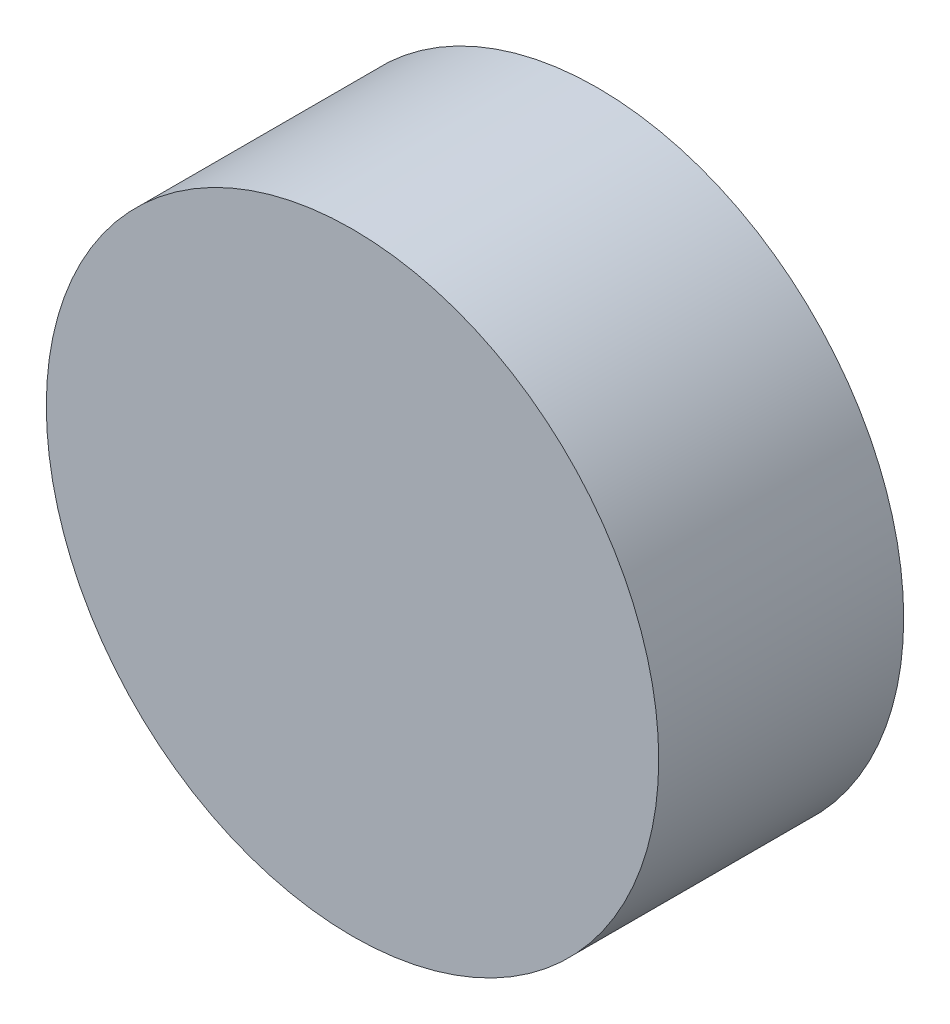
from build123d import *

# Parameters (mm, degrees)
SKIZZE1_R                       = 2.5
AUFSATZ_LINEAR_AUSTRAGEN1_DEPTH = 2


with BuildPart() as part:
    # Skizze1 → Aufsatz-Linear austragen1 (new body)
    with BuildSketch(Plane.XY):
        Circle(SKIZZE1_R)
    extrude(amount=AUFSATZ_LINEAR_AUSTRAGEN1_DEPTH)


solid = part.part
